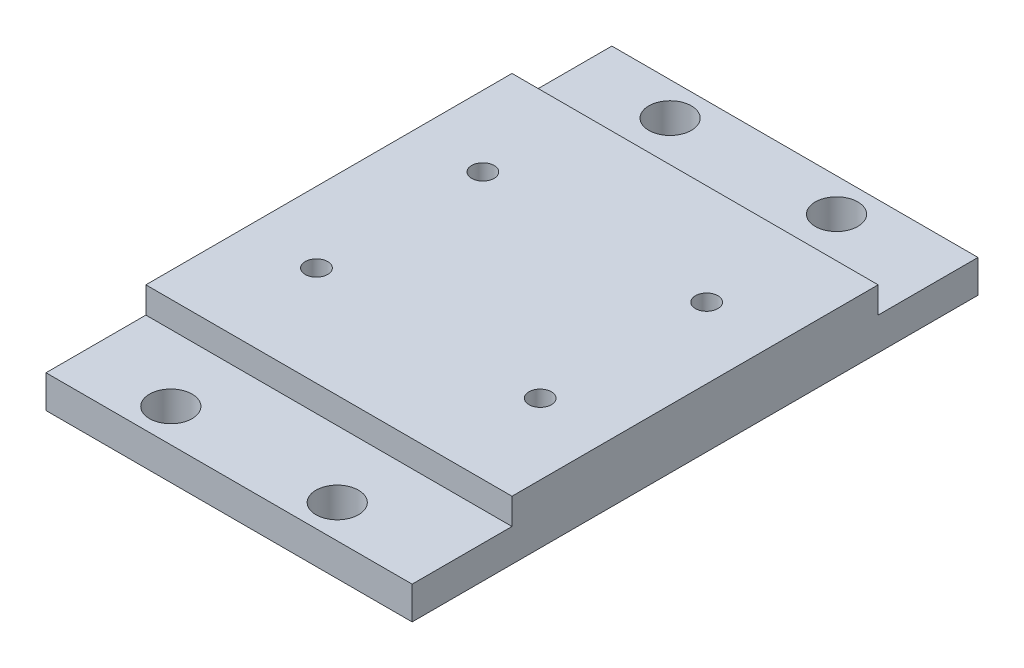
from build123d import *

# Parameters (mm, degrees)
SKETCH1_W                          = 55.88
SKETCH1_H                          = 55.88
BOSS_EXTRUDE1_DEPTH                = 9
F_1_4_0_25_CLEARANCE_DOWEL_HOLE1_D = 3.429
SKETCH4_W                          = 44.289451808
SKETCH4_H                          = 35.4
CUT_EXTRUDE1_DEPTH                 = 4
SKETCH5_W                          = 55.88
SKETCH5_H                          = 5
BOSS_EXTRUDE2_DEPTH                = 15.24
SKETCH6_W                          = 55.88
SKETCH6_H                          = 5
BOSS_EXTRUDE3_DEPTH                = 15.24
F_1_4_0_25_CLEARANCE_DOWEL_HOLE2_D = 6.499999954


with BuildPart() as part:
    # Sketch1 → Boss-Extrude1 (new body)
    with BuildSketch(Plane(origin=(0, 0, 0), x_dir=(1, 0, 0), z_dir=(0, 1, 0))):
        Rectangle(SKETCH1_W, SKETCH1_H)
    extrude(amount=BOSS_EXTRUDE1_DEPTH)

    # 1/4 (0.25) Clearance Dowel Hole1 (through all)
    with Locations(Plane(origin=(0, 9, 0), x_dir=(1, 0, 0), z_dir=(0, 1, 0))):
        with Locations((-17.144725904, -12.7), (-17.144725904, 12.7), (17.145, -12.837103678), (17.145, 12.562896322)):
            Hole(F_1_4_0_25_CLEARANCE_DOWEL_HOLE1_D / 2)

    # Sketch4 → Cut-Extrude1 (cut)
    with BuildSketch(Plane.XZ):
        Rectangle(SKETCH4_W, SKETCH4_H)
    extrude(amount=-CUT_EXTRUDE1_DEPTH, mode=Mode.SUBTRACT)

    # Sketch5 → Boss-Extrude2 (add)
    with BuildSketch(Plane.XY.offset(27.94)):
        with Locations((0, 2.5)):
            Rectangle(SKETCH5_W, SKETCH5_H)
    extrude(amount=BOSS_EXTRUDE2_DEPTH)

    # Sketch6 → Boss-Extrude3 (add)
    with BuildSketch(Plane(origin=(0, 0, -27.94), x_dir=(-1, 0, 0), z_dir=(0, 0, -1))):
        with Locations((0, 2.5)):
            Rectangle(SKETCH6_W, SKETCH6_H)
    extrude(amount=BOSS_EXTRUDE3_DEPTH)

    # 1/4 (0.25) Clearance Dowel Hole2 (through all)
    with Locations(Plane(origin=(0, 5, 0), x_dir=(1, 0, 0), z_dir=(0, 1, 0))):
        with Locations((11.43, 38.1), (-13.97, 38.1), (-13.97, -38.1), (11.43, -38.1)):
            Hole(F_1_4_0_25_CLEARANCE_DOWEL_HOLE2_D / 2)


solid = part.part
